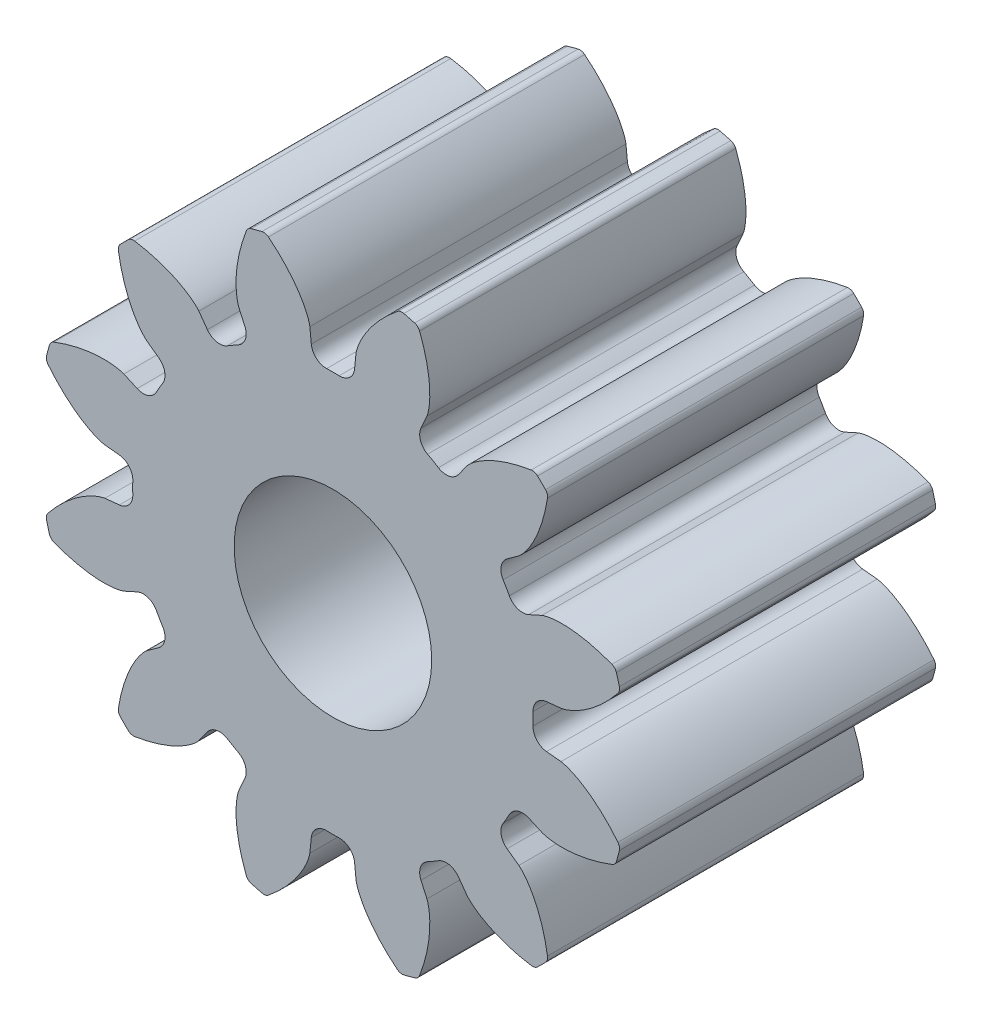
from build123d import *

# Parameters (mm, degrees)
SKETCH1_R                                 = 11.853333333
BOSS_EXTRUDE1_DEPTH                       = 12.7
CUT_EXTRUDE_DCLTBC_DEPTH                  = 13.7
FILLET_TIP_DCLTBC_R                       = 0.301120865
FILLET_ROOT_DCLTBC_R                      = 0.602241731
CIRPATTERN_DCLTBC_COUNT                   = 12
FILLET_TIP_DCLTBC_OF_CIRPATTERN_DCLTBC_R  = 0.301120865
FILLET_ROOT_DCLTBC_OF_CIRPATTERN_DCLTBC_R = 0.602241731
SKETCH8_R                                 = 3.96875
CUT_EXTRUDE5_DEPTH                        = 25.4


with BuildPart() as part:
    # Sketch1 → Boss-Extrude1 (new body)
    with BuildSketch(Plane.XY):
        Circle(SKETCH1_R)
    extrude(amount=BOSS_EXTRUDE1_DEPTH)

    # DCLTBC → Cut-Extrude-DCLTBC (cut, through all)
    with BuildSketch(Plane.XY):
        with BuildLine():
            Line((-0.927743365, 9.16123139), (-0.810390806, 8.002404504))
            ThreePointArc((-0.810390806, 8.002404504), (0, 8.043333333), (0.810390806, 8.002404504))
            Line((0.810390806, 8.002404504), (0.927743365, 9.16123139))
            add(Edge.make_bspline(
                [(0.927743365, 9.16123139), (0.928270372, 9.165673983), (0.929984249, 9.178104902), (0.934154408, 9.201482103), (0.942272678, 9.239404048), (0.95453976, 9.287358179), (0.97258884, 9.348853599), (0.99665505, 9.420608876), (1.026018144, 9.498665989), (1.061081726, 9.582644473), (1.098798006, 9.665527918), (1.138943653, 9.747315392), (1.181195241, 9.827946033), (1.235016859, 9.924559354), (1.303210394, 10.038900187), (1.38815898, 10.170192354), (1.490627, 10.316197145), (1.601467698, 10.461683871), (1.715760673, 10.602046337), (1.837096668, 10.740448036), (1.958640091, 10.871922616), (2.090694707, 11.004746474), (2.215561338, 11.125464492), (2.361691224, 11.256359858), (2.481459017, 11.360740357), (2.610240501, 11.464797066), (2.673658985, 11.514879464), (2.706378605, 11.540235091)],
                knots=[0, 0, 0, 0, 0, 0.005376749, 0.015083688, 0.02853182, 0.046610139, 0.064854849, 0.092110525, 0.119476176, 0.146842496, 0.174208854, 0.201574955, 0.228941013, 0.256307345, 0.307035032, 0.361767352, 0.41649966, 0.471231936, 0.525964282, 0.580696615, 0.635428982, 0.690161387, 0.744893688, 0.799626082, 0.854358408, 0.909090915, 0.909090915, 0.909090915, 0.909090915, 0.909090915], degree=4))
            ThreePointArc((2.706378605, 11.540235091), (0, 11.853333333), (-2.706378605, 11.540235091))
            add(Edge.make_bspline(
                [(-0.927743365, 9.16123139), (-0.928270372, 9.165673983), (-0.929984249, 9.178104902), (-0.934154408, 9.201482103), (-0.942272678, 9.239404048), (-0.95453976, 9.287358179), (-0.97258884, 9.348853599), (-0.99665505, 9.420608876), (-1.026018144, 9.498665989), (-1.061081726, 9.582644473), (-1.098798006, 9.665527918), (-1.138943653, 9.747315392), (-1.181195241, 9.827946033), (-1.235016859, 9.924559354), (-1.303210394, 10.038900187), (-1.38815898, 10.170192354), (-1.490627, 10.316197145), (-1.601467698, 10.461683871), (-1.715760673, 10.602046337), (-1.837096668, 10.740448036), (-1.958640091, 10.871922616), (-2.090694707, 11.004746474), (-2.215561338, 11.125464492), (-2.361691224, 11.256359858), (-2.481459017, 11.360740357), (-2.610240501, 11.464797066), (-2.673658985, 11.514879464), (-2.706378605, 11.540235091)],
                knots=[0, 0, 0, 0, 0, 0.005376749, 0.015083688, 0.02853182, 0.046610139, 0.064854849, 0.092110525, 0.119476176, 0.146842496, 0.174208854, 0.201574955, 0.228941013, 0.256307345, 0.307035032, 0.361767352, 0.41649966, 0.471231936, 0.525964282, 0.580696615, 0.635428982, 0.690161387, 0.744893688, 0.799626082, 0.854358408, 0.909090915, 0.909090915, 0.909090915, 0.909090915, 0.909090915], degree=4))
        make_face()
    cut_extrude_dcltbc = extrude(amount=CUT_EXTRUDE_DCLTBC_DEPTH, mode=Mode.SUBTRACT)

    # Fillet-Tip-DCLTBC
    fillet_tip_dcltbc_edges = [part.edges().sort_by_distance(p)[0] for p in [
        (2.706378605, 11.540235091, 6.35),
        (-2.706378605, 11.540235091, 6.35),
    ]]
    fillet(fillet_tip_dcltbc_edges, radius=FILLET_TIP_DCLTBC_R)

    # Fillet-Root-DCLTBC
    fillet_root_dcltbc_edges = [part.edges().sort_by_distance(p)[0] for p in [
        (0.810390806, 8.002404504, 6.35),
        (-0.810390806, 8.002404504, 6.35),
    ]]
    fillet(fillet_root_dcltbc_edges, radius=FILLET_ROOT_DCLTBC_R)

    # CirPattern-DCLTBC: Cut-Extrude-DCLTBC ×12 about axis
    cirpattern_dcltbc_axis = Axis((0, 0, 12.7), (0, 0, 1))
    for i in range(1, CIRPATTERN_DCLTBC_COUNT):
        add(cut_extrude_dcltbc.rotate(cirpattern_dcltbc_axis, i * 360 / CIRPATTERN_DCLTBC_COUNT), mode=Mode.SUBTRACT)

    # Fillet-Tip-DCLTBC of CirPattern-DCLTBC
    fillet_tip_dcltbc_of_cirpattern_dcltbc_edges = [part.edges().sort_by_distance(p)[0] for p in [
        (-3.426324921, 11.347326057, 6.35),
        (-8.11391017, 8.640947452, 6.35),
        (-8.640947452, 8.11391017, 6.35),
        (-11.347326057, 3.426324921, 6.35),
        (-11.540235091, 2.706378605, 6.35),
        (-11.540235091, -2.706378605, 6.35),
        (-11.347326057, -3.426324921, 6.35),
        (-8.640947452, -8.11391017, 6.35),
        (-8.11391017, -8.640947452, 6.35),
        (-3.426324921, -11.347326057, 6.35),
        (-2.706378605, -11.540235091, 6.35),
        (2.706378605, -11.540235091, 6.35),
        (3.426324921, -11.347326057, 6.35),
        (8.11391017, -8.640947452, 6.35),
        (8.640947452, -8.11391017, 6.35),
        (11.347326057, -3.426324921, 6.35),
        (11.540235091, -2.706378605, 6.35),
        (11.540235091, 2.706378605, 6.35),
        (11.347326057, 3.426324921, 6.35),
        (8.640947452, 8.11391017, 6.35),
        (8.11391017, 8.640947452, 6.35),
        (3.426324921, 11.347326057, 6.35),
    ]]
    fillet(fillet_tip_dcltbc_of_cirpattern_dcltbc_edges, radius=FILLET_TIP_DCLTBC_OF_CIRPATTERN_DCLTBC_R)

    # Fillet-Root-DCLTBC of CirPattern-DCLTBC
    fillet_root_dcltbc_of_cirpattern_dcltbc_edges = [part.edges().sort_by_distance(p)[0] for p in [
        (-3.299383228, 7.335480995, 6.35),
        (-4.703021277, 6.525090189, 6.35),
        (-6.525090189, 4.703021277, 6.35),
        (-7.335480995, 3.299383228, 6.35),
        (-8.002404504, 0.810390806, 6.35),
        (-8.002404504, -0.810390806, 6.35),
        (-7.335480995, -3.299383228, 6.35),
        (-6.525090189, -4.703021277, 6.35),
        (-4.703021277, -6.525090189, 6.35),
        (-3.299383228, -7.335480995, 6.35),
        (-0.810390806, -8.002404504, 6.35),
        (0.810390806, -8.002404504, 6.35),
        (3.299383228, -7.335480995, 6.35),
        (4.703021277, -6.525090189, 6.35),
        (6.525090189, -4.703021277, 6.35),
        (7.335480995, -3.299383228, 6.35),
        (8.002404504, -0.810390806, 6.35),
        (8.002404504, 0.810390806, 6.35),
        (7.335480995, 3.299383228, 6.35),
        (6.525090189, 4.703021277, 6.35),
        (4.703021277, 6.525090189, 6.35),
        (3.299383228, 7.335480995, 6.35),
    ]]
    fillet(fillet_root_dcltbc_of_cirpattern_dcltbc_edges, radius=FILLET_ROOT_DCLTBC_OF_CIRPATTERN_DCLTBC_R)

    # Sketch8 → Cut-Extrude5 (cut)
    with BuildSketch(Plane.XY):
        Circle(SKETCH8_R)
    extrude(amount=CUT_EXTRUDE5_DEPTH, mode=Mode.SUBTRACT)


solid = part.part
